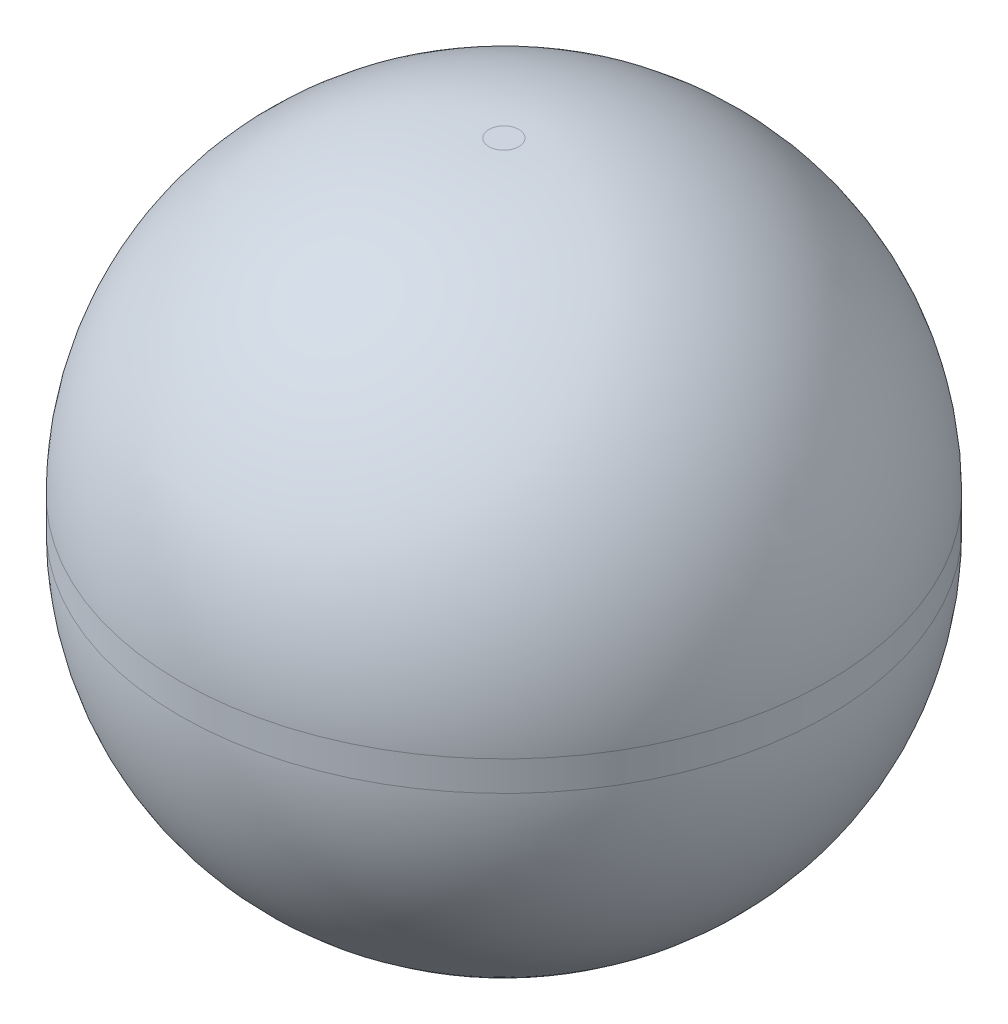
from build123d import *

# Parameters (mm, degrees)
ESQUISSE1_R      = 32.5
EXTRUSION1_DEPTH = 65
CONG_1_R         = 31


with BuildPart() as part:
    # Esquisse1 → Extrusion1 (new body)
    with BuildSketch(Plane(origin=(0, 0, 0), x_dir=(1, 0, 0), z_dir=(0, 1, 0))):
        Circle(ESQUISSE1_R)
    extrude(amount=EXTRUSION1_DEPTH)

    # Congé1
    cong_1_edges = [part.edges().sort_by_distance(p)[0] for p in [
        (-32.5, 0, 0),
        (-32.5, 65, 0),
    ]]
    fillet(cong_1_edges, radius=CONG_1_R)


solid = part.part
